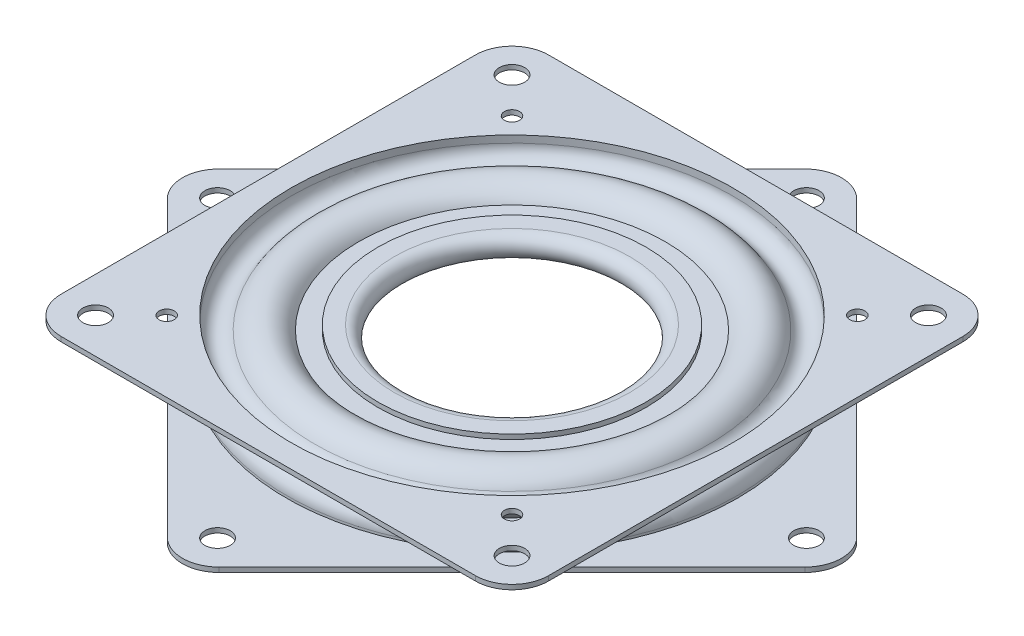
from build123d import *

# Parameters (mm, degrees)
BOSS_EXTRUDE1_START     = -0.7366
SKETCH4_W               = 76.2
SKETCH4_H               = 76.2
SKETCH4_R               = 34.517709056
BOSS_EXTRUDE1_DEPTH     = 0.7366
BOSS_EXTRUDE2_START     = -0.736601
SKETCH5_R               = 34.517709056
BOSS_EXTRUDE2_DEPTH     = 0.736602
SKETCH6_R               = 1.984375
SKETCH6_R_2             = 1.190625
CUT_EXTRUDE1_DEPTH      = 4.9370001
CUT_EXTRUDE1_DEPTH_BACK = 4.937001
SKETCH7_R               = 1.984375
CUT_EXTRUDE2_DEPTH      = 4.9370001
CUT_EXTRUDE2_DEPTH_BACK = 4.937001
CIRPATTERN1_COUNT       = 22
FILLET1_R               = 5.715
FILLET2_R               = 5.715


with BuildPart() as part:
    # Sketch3 → Revolve-Thin1 (revolve)
    with BuildSketch(Plane.XY):
        with BuildLine():
            Line((38.1, -3.937), (34.517709056, -3.937))
            Line((34.517709056, -3.937), (34.517709056, -2.83464))
            ThreePointArc((34.517709056, -2.83464), (33.036848091, -0.927495427), (30.822306037, -1.88976))
            ThreePointArc((30.822306037, -1.88976), (26.821379497, -3.898798296), (23.527957004, -0.86614))
            Line((23.527957004, -0.86614), (18.40865, -0.86614))
            ThreePointArc((18.40865, -0.86614), (16.637, 0.90551), (18.40865, 2.67716))
            Line((18.40865, 2.67716), (20.968303502, 2.67716))
            Line((20.968303502, 2.67716), (20.968303502, 1.94056))
            Line((20.968303502, 1.94056), (18.40865, 1.94056))
            ThreePointArc((18.40865, 1.94056), (17.3736, 0.90551), (18.40865, -0.12954))
            Line((18.40865, -0.12954), (24.170722718, -0.12954))
            ThreePointArc((24.170722718, -0.12954), (26.638619821, -3.116060828), (30.176110069, -1.536192))
            ThreePointArc((30.176110069, -1.536192), (33.219319472, -0.213854232), (35.254309056, -2.83464))
            Line((35.254309056, -2.83464), (35.254309056, -3.2004))
            Line((35.254309056, -3.2004), (38.1, -3.2004))
            Line((38.1, -3.2004), (38.1, -3.937))
        make_face()
    revolve(axis=Axis((0, 3.937, 0), (0, -1, 0)))

    # Sketch5 → Boss-Extrude2 (add)
    with BuildSketch(Plane.XZ.offset(3.937).offset(BOSS_EXTRUDE2_START)):
        Polygon((-53.881536726, 0), (0, 53.881536726), (53.881536726, 0), (0, -53.881536726), align=None)
        Circle(SKETCH5_R, mode=Mode.SUBTRACT)
    extrude(amount=BOSS_EXTRUDE2_DEPTH)

    # Sketch7 → Cut-Extrude2 (cut, two sides)
    with BuildSketch(Plane(origin=(0, 0, 0), x_dir=(1, 0, 0), z_dir=(0, 1, 0))) as cut_extrude2_sk:
        with Locations((46.02381262, 0)):
            Circle(SKETCH7_R)
        with Locations((0, 46.02381262)):
            Circle(SKETCH7_R)
        with Locations((-46.02381262, 0)):
            Circle(SKETCH7_R)
        with Locations((0, -46.02381262)):
            Circle(SKETCH7_R)
    extrude(amount=CUT_EXTRUDE2_DEPTH, mode=Mode.SUBTRACT)
    extrude(cut_extrude2_sk.sketch, amount=-CUT_EXTRUDE2_DEPTH_BACK, mode=Mode.SUBTRACT)

    # Fillet2
    fillet2_edges = [part.edges().sort_by_distance(p)[0] for p in [
        (0, -3.5687, -53.881536726),
        (-53.881536726, -3.5687, 0),
        (0, -3.5687, 53.881536726),
        (53.881536726, -3.5687, 0),
    ]]
    fillet(fillet2_edges, radius=FILLET2_R)


with BuildPart() as body_2:
    # Sketch3_3 → Revolve-Thin2 (revolve)
    with BuildSketch(Plane.XY):
        with BuildLine():
            Line((38.1, 3.937), (34.517709056, 3.937))
            Line((34.517709056, 3.937), (34.517709056, 2.83464))
            ThreePointArc((34.517709056, 2.83464), (33.036848091, 0.927495427), (30.822306037, 1.88976))
            ThreePointArc((30.822306037, 1.88976), (27.397571759, 3.936892662), (23.942978742, 1.94056))
            Line((23.942978742, 1.94056), (18.40865, 1.94056))
            Line((18.40865, 1.94056), (18.40865, 1.20396))
            Line((18.40865, 1.20396), (24.403193864, 1.20396))
            ThreePointArc((24.403193864, 1.20396), (27.184620861, 3.195113241), (30.176110069, 1.536192))
            ThreePointArc((30.176110069, 1.536192), (33.219319472, 0.213854232), (35.254309056, 2.83464))
            Line((35.254309056, 2.83464), (35.254309056, 3.2004))
            Line((35.254309056, 3.2004), (38.1, 3.2004))
            Line((38.1, 3.2004), (38.1, 3.937))
        make_face()
    revolve(axis=Axis((0, 3.937, 0), (0, -1, 0)))

    # Sketch4 → Boss-Extrude1 (add)
    with BuildSketch(Plane(origin=(0, 3.937, 0), x_dir=(1, 0, 0), z_dir=(0, 1, 0)).offset(BOSS_EXTRUDE1_START)):
        Rectangle(SKETCH4_W, SKETCH4_H)
        Circle(SKETCH4_R, mode=Mode.SUBTRACT)
    extrude(amount=BOSS_EXTRUDE1_DEPTH)

    # Sketch6 → Cut-Extrude1 (cut, two sides)
    with BuildSketch(Plane(origin=(0, 0, 0), x_dir=(1, 0, 0), z_dir=(0, 1, 0))) as cut_extrude1_sk:
        with Locations((-32.54375, 32.54375)):
            Circle(SKETCH6_R)
        with Locations((-32.54375, -32.54375)):
            Circle(SKETCH6_R)
        with Locations((32.54375, -32.54375)):
            Circle(SKETCH6_R)
        with Locations((32.54375, 32.54375)):
            Circle(SKETCH6_R)
        with Locations((26.9875, 26.9875)):
            Circle(SKETCH6_R_2)
        with Locations((-26.9875, 26.9875)):
            Circle(SKETCH6_R_2)
        with Locations((26.9875, -26.9875)):
            Circle(SKETCH6_R_2)
        with Locations((-26.9875, -26.9875)):
            Circle(SKETCH6_R_2)
    extrude(amount=CUT_EXTRUDE1_DEPTH, mode=Mode.SUBTRACT)
    extrude(cut_extrude1_sk.sketch, amount=-CUT_EXTRUDE1_DEPTH_BACK, mode=Mode.SUBTRACT)

    # Fillet1
    fillet1_edges = [body_2.edges().sort_by_distance(p)[0] for p in [
        (-38.1, 3.5687, 38.1),
        (-38.1, 3.5687, -38.1),
        (38.1, 3.5687, -38.1),
        (38.1, 3.5687, 38.1),
    ]]
    fillet(fillet1_edges, radius=FILLET1_R)


with BuildPart() as body_3:
    # Sketch8 → Revolve1 (revolve)
    with BuildSketch(Plane.XY):
        with BuildLine():
            Line((27.3685, 3.683), (27.3685, -3.683))
            ThreePointArc((27.3685, -3.683), (31.0515, 0), (27.3685, 3.683))
        make_face()
    revolve(axis=Axis((27.3685, 3.683, 0), (0, -1, 0)))


with BuildPart() as cirpattern1_1:
    # CirPattern1: pattern copy
    add(body_3.part.rotate(Axis((0, 0, 0), (0, 1, 0)), 1 * 360 / CIRPATTERN1_COUNT))


with BuildPart() as cirpattern1_2:
    # CirPattern1: pattern copy
    add(body_3.part.rotate(Axis((0, 0, 0), (0, 1, 0)), 2 * 360 / CIRPATTERN1_COUNT))


with BuildPart() as cirpattern1_3:
    # CirPattern1: pattern copy
    add(body_3.part.rotate(Axis((0, 0, 0), (0, 1, 0)), 3 * 360 / CIRPATTERN1_COUNT))


with BuildPart() as cirpattern1_4:
    # CirPattern1: pattern copy
    add(body_3.part.rotate(Axis((0, 0, 0), (0, 1, 0)), 4 * 360 / CIRPATTERN1_COUNT))


with BuildPart() as cirpattern1_5:
    # CirPattern1: pattern copy
    add(body_3.part.rotate(Axis((0, 0, 0), (0, 1, 0)), 5 * 360 / CIRPATTERN1_COUNT))


with BuildPart() as cirpattern1_6:
    # CirPattern1: pattern copy
    add(body_3.part.rotate(Axis((0, 0, 0), (0, 1, 0)), 6 * 360 / CIRPATTERN1_COUNT))


with BuildPart() as cirpattern1_7:
    # CirPattern1: pattern copy
    add(body_3.part.rotate(Axis((0, 0, 0), (0, 1, 0)), 7 * 360 / CIRPATTERN1_COUNT))


with BuildPart() as cirpattern1_8:
    # CirPattern1: pattern copy
    add(body_3.part.rotate(Axis((0, 0, 0), (0, 1, 0)), 8 * 360 / CIRPATTERN1_COUNT))


with BuildPart() as cirpattern1_9:
    # CirPattern1: pattern copy
    add(body_3.part.rotate(Axis((0, 0, 0), (0, 1, 0)), 9 * 360 / CIRPATTERN1_COUNT))


with BuildPart() as cirpattern1_10:
    # CirPattern1: pattern copy
    add(body_3.part.rotate(Axis((0, 0, 0), (0, 1, 0)), 10 * 360 / CIRPATTERN1_COUNT))


with BuildPart() as cirpattern1_11:
    # CirPattern1: pattern copy
    add(body_3.part.rotate(Axis((0, 0, 0), (0, 1, 0)), 11 * 360 / CIRPATTERN1_COUNT))


with BuildPart() as cirpattern1_12:
    # CirPattern1: pattern copy
    add(body_3.part.rotate(Axis((0, 0, 0), (0, 1, 0)), 12 * 360 / CIRPATTERN1_COUNT))


with BuildPart() as cirpattern1_13:
    # CirPattern1: pattern copy
    add(body_3.part.rotate(Axis((0, 0, 0), (0, 1, 0)), 13 * 360 / CIRPATTERN1_COUNT))


with BuildPart() as cirpattern1_14:
    # CirPattern1: pattern copy
    add(body_3.part.rotate(Axis((0, 0, 0), (0, 1, 0)), 14 * 360 / CIRPATTERN1_COUNT))


with BuildPart() as cirpattern1_15:
    # CirPattern1: pattern copy
    add(body_3.part.rotate(Axis((0, 0, 0), (0, 1, 0)), 15 * 360 / CIRPATTERN1_COUNT))


with BuildPart() as cirpattern1_16:
    # CirPattern1: pattern copy
    add(body_3.part.rotate(Axis((0, 0, 0), (0, 1, 0)), 16 * 360 / CIRPATTERN1_COUNT))


with BuildPart() as cirpattern1_17:
    # CirPattern1: pattern copy
    add(body_3.part.rotate(Axis((0, 0, 0), (0, 1, 0)), 17 * 360 / CIRPATTERN1_COUNT))


with BuildPart() as cirpattern1_18:
    # CirPattern1: pattern copy
    add(body_3.part.rotate(Axis((0, 0, 0), (0, 1, 0)), 18 * 360 / CIRPATTERN1_COUNT))


with BuildPart() as cirpattern1_19:
    # CirPattern1: pattern copy
    add(body_3.part.rotate(Axis((0, 0, 0), (0, 1, 0)), 19 * 360 / CIRPATTERN1_COUNT))


with BuildPart() as cirpattern1_20:
    # CirPattern1: pattern copy
    add(body_3.part.rotate(Axis((0, 0, 0), (0, 1, 0)), 20 * 360 / CIRPATTERN1_COUNT))


with BuildPart() as cirpattern1_21:
    # CirPattern1: pattern copy
    add(body_3.part.rotate(Axis((0, 0, 0), (0, 1, 0)), 21 * 360 / CIRPATTERN1_COUNT))


solid = Compound([part.part, body_2.part, body_3.part, cirpattern1_1.part, cirpattern1_2.part, cirpattern1_3.part, cirpattern1_4.part, cirpattern1_5.part, cirpattern1_6.part, cirpattern1_7.part, cirpattern1_8.part, cirpattern1_9.part, cirpattern1_10.part, cirpattern1_11.part, cirpattern1_12.part, cirpattern1_13.part, cirpattern1_14.part, cirpattern1_15.part, cirpattern1_16.part, cirpattern1_17.part, cirpattern1_18.part, cirpattern1_19.part, cirpattern1_20.part, cirpattern1_21.part])
